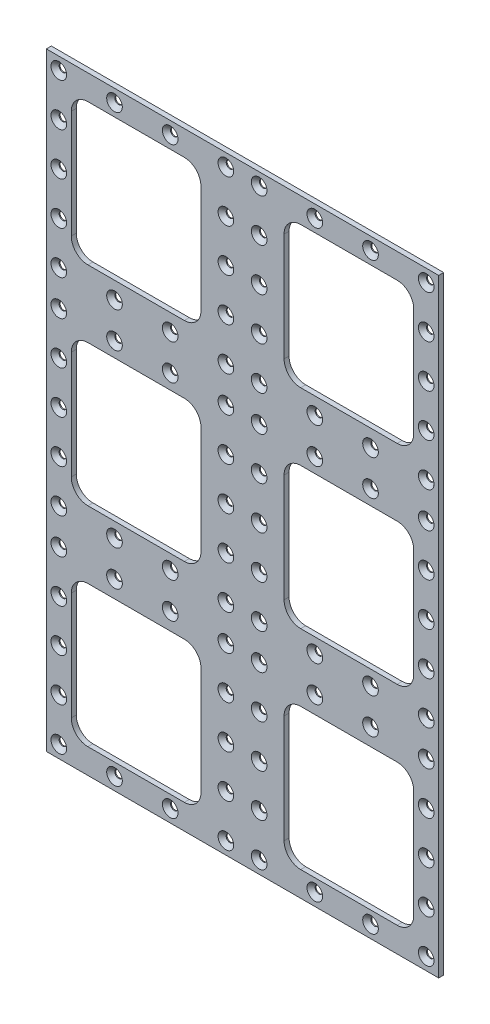
from build123d import *

# Parameters (mm, degrees)
SKETCH1_W              = 236
SKETCH1_H              = 366
BOSS_EXTRUDE1_DEPTH    = 3
SKETCH2_W              = 78
SKETCH2_H              = 85
CUT_EXTRUDE4_DEPTH     = 4
FILLET1_R              = 10
LPATTERN1_COUNT        = 3
LPATTERN1_PITCH        = 125.5
LPATTERN1_COUNT_DIR2   = 2
LPATTERN1_PITCH_DIR2   = 128
FILLET1_OF_LPATTERN1_R = 10
LPATTERN5_COUNT        = 4
LPATTERN5_PITCH        = 33.5
LPATTERN5_COUNT_DIR2   = 5
LPATTERN5_PITCH_DIR2   = 25.6875
LPATTERN6_COUNT        = 3
LPATTERN6_PITCH        = 124.125


with BuildPart() as part:
    # Sketch1 → Boss-Extrude1 (new body)
    with BuildSketch(Plane.XY):
        Rectangle(SKETCH1_W, SKETCH1_H)
    extrude(amount=BOSS_EXTRUDE1_DEPTH)

    # Sketch2 → Cut-Extrude4 (cut, through all)
    with BuildSketch(Plane.XY):
        with Locations((-64, 125.5)):
            Rectangle(SKETCH2_W, SKETCH2_H)
    cut_extrude4 = extrude(amount=CUT_EXTRUDE4_DEPTH, mode=Mode.SUBTRACT)

    # Fillet1
    fillet1_edges = [part.edges().sort_by_distance(p)[0] for p in [
        (-25, 83, 1.5),
        (-25, 168, 1.5),
        (-103, 168, 1.5),
        (-103, 83, 1.5),
    ]]
    fillet(fillet1_edges, radius=FILLET1_R)

    # LPattern1: Cut-Extrude4 3 × 2
    with Locations(*[(j * LPATTERN1_PITCH_DIR2, -i * LPATTERN1_PITCH, 0) for i in range(LPATTERN1_COUNT) for j in range(LPATTERN1_COUNT_DIR2) if (i, j) != (0, 0)]):
        add(cut_extrude4, mode=Mode.SUBTRACT)

    # Fillet1 of LPattern1
    fillet1_of_lpattern1_edges = [part.edges().sort_by_distance(p)[0] for p in [
        (103, 83, 1.5),
        (103, 168, 1.5),
        (25, 168, 1.5),
        (25, 83, 1.5),
        (-25, -42.5, 1.5),
        (-25, 42.5, 1.5),
        (-103, 42.5, 1.5),
        (-103, -42.5, 1.5),
        (103, -42.5, 1.5),
        (103, 42.5, 1.5),
        (25, 42.5, 1.5),
        (25, -42.5, 1.5),
        (-25, -168, 1.5),
        (-25, -83, 1.5),
        (-103, -83, 1.5),
        (-103, -168, 1.5),
        (103, -168, 1.5),
        (103, -83, 1.5),
        (25, -83, 1.5),
        (25, -168, 1.5),
    ]]
    fillet(fillet1_of_lpattern1_edges, radius=FILLET1_OF_LPATTERN1_R)

    # Sketch8 → CSK for M4 Flat Head Machine Screw3 (revolve, cut)
    with BuildSketch(Plane(origin=(-110.5, 175.5, 3), x_dir=(0, -1, 0), z_dir=(1, 0, 0))):
        Polygon((0, 0), (0, 3), (2.25, 3), (2.25, 2.45), (4.7, 0), align=None)
    csk_for_m4_flat_head_machine_screw3 = revolve(axis=Axis((-110.5, 175.5, 9.35), (0, 0, -1)), mode=Mode.SUBTRACT)

    # LPattern5: CSK for M4 Flat Head Machine Screw3 4 × 5, 6 skipped
    with Locations(*[(i * LPATTERN5_PITCH, -j * LPATTERN5_PITCH_DIR2, 0) for i in range(LPATTERN5_COUNT) for j in range(LPATTERN5_COUNT_DIR2) if (i, j) not in ((0, 0), (1, 1), (1, 2), (1, 3), (2, 1), (2, 2), (2, 3))]):
        add(csk_for_m4_flat_head_machine_screw3, mode=Mode.SUBTRACT)

    # LPattern6: CSK for M4 Flat Head Machine Screw3 ×3
    with Locations(*[(0, -i * LPATTERN6_PITCH, 0) for i in range(1, LPATTERN6_COUNT)]):
        add(csk_for_m4_flat_head_machine_screw3, mode=Mode.SUBTRACT)

    # LPattern6 copy 1 sketch → LPattern6 copy 1 (revolve, cut)
    with BuildSketch(Plane(origin=(-110.5, 25.6875, 3), x_dir=(0, -1, 0), z_dir=(1, 0, 0))):
        Polygon((0, 0), (0, 3), (2.25, 3), (2.25, 2.45), (4.7, 0), align=None)
    revolve(axis=Axis((-110.5, 25.6875, 9.35), (0, 0, -1)), mode=Mode.SUBTRACT)

    # LPattern6 copy 2 sketch → LPattern6 copy 2 (revolve, cut)
    with BuildSketch(Plane(origin=(-110.5, -98.4375, 3), x_dir=(0, -1, 0), z_dir=(1, 0, 0))):
        Polygon((0, 0), (0, 3), (2.25, 3), (2.25, 2.45), (4.7, 0), align=None)
    revolve(axis=Axis((-110.5, -98.4375, 9.35), (0, 0, -1)), mode=Mode.SUBTRACT)

    # LPattern6 copy 3 sketch → LPattern6 copy 3 (revolve, cut)
    with BuildSketch(Plane(origin=(-110.5, 0, 3), x_dir=(0, -1, 0), z_dir=(1, 0, 0))):
        Polygon((0, 0), (0, 3), (2.25, 3), (2.25, 2.45), (4.7, 0), align=None)
    revolve(axis=Axis((-110.5, 0, 9.35), (0, 0, -1)), mode=Mode.SUBTRACT)

    # LPattern6 copy 4 sketch → LPattern6 copy 4 (revolve, cut)
    with BuildSketch(Plane(origin=(-110.5, -124.125, 3), x_dir=(0, -1, 0), z_dir=(1, 0, 0))):
        Polygon((0, 0), (0, 3), (2.25, 3), (2.25, 2.45), (4.7, 0), align=None)
    revolve(axis=Axis((-110.5, -124.125, 9.35), (0, 0, -1)), mode=Mode.SUBTRACT)

    # LPattern6 copy 5 sketch → LPattern6 copy 5 (revolve, cut)
    with BuildSketch(Plane(origin=(-110.5, -25.6875, 3), x_dir=(0, -1, 0), z_dir=(1, 0, 0))):
        Polygon((0, 0), (0, 3), (2.25, 3), (2.25, 2.45), (4.7, 0), align=None)
    revolve(axis=Axis((-110.5, -25.6875, 9.35), (0, 0, -1)), mode=Mode.SUBTRACT)

    # LPattern6 copy 6 sketch → LPattern6 copy 6 (revolve, cut)
    with BuildSketch(Plane(origin=(-110.5, -149.8125, 3), x_dir=(0, -1, 0), z_dir=(1, 0, 0))):
        Polygon((0, 0), (0, 3), (2.25, 3), (2.25, 2.45), (4.7, 0), align=None)
    revolve(axis=Axis((-110.5, -149.8125, 9.35), (0, 0, -1)), mode=Mode.SUBTRACT)

    # LPattern6 copy 7 sketch → LPattern6 copy 7 (revolve, cut)
    with BuildSketch(Plane(origin=(-110.5, -51.375, 3), x_dir=(0, -1, 0), z_dir=(1, 0, 0))):
        Polygon((0, 0), (0, 3), (2.25, 3), (2.25, 2.45), (4.7, 0), align=None)
    revolve(axis=Axis((-110.5, -51.375, 9.35), (0, 0, -1)), mode=Mode.SUBTRACT)

    # LPattern6 copy 8 sketch → LPattern6 copy 8 (revolve, cut)
    with BuildSketch(Plane(origin=(-110.5, -175.5, 3), x_dir=(0, -1, 0), z_dir=(1, 0, 0))):
        Polygon((0, 0), (0, 3), (2.25, 3), (2.25, 2.45), (4.7, 0), align=None)
    revolve(axis=Axis((-110.5, -175.5, 9.35), (0, 0, -1)), mode=Mode.SUBTRACT)

    # LPattern6 copy 9 sketch → LPattern6 copy 9 (revolve, cut)
    with BuildSketch(Plane(origin=(-77, 51.375, 3), x_dir=(0, -1, 0), z_dir=(1, 0, 0))):
        Polygon((0, 0), (0, 3), (2.25, 3), (2.25, 2.45), (4.7, 0), align=None)
    revolve(axis=Axis((-77, 51.375, 9.35), (0, 0, -1)), mode=Mode.SUBTRACT)

    # LPattern6 copy 10 sketch → LPattern6 copy 10 (revolve, cut)
    with BuildSketch(Plane(origin=(-77, -72.75, 3), x_dir=(0, -1, 0), z_dir=(1, 0, 0))):
        Polygon((0, 0), (0, 3), (2.25, 3), (2.25, 2.45), (4.7, 0), align=None)
    revolve(axis=Axis((-77, -72.75, 9.35), (0, 0, -1)), mode=Mode.SUBTRACT)

    # LPattern6 copy 11 sketch → LPattern6 copy 11 (revolve, cut)
    with BuildSketch(Plane(origin=(-77, -51.375, 3), x_dir=(0, -1, 0), z_dir=(1, 0, 0))):
        Polygon((0, 0), (0, 3), (2.25, 3), (2.25, 2.45), (4.7, 0), align=None)
    revolve(axis=Axis((-77, -51.375, 9.35), (0, 0, -1)), mode=Mode.SUBTRACT)

    # LPattern6 copy 12 sketch → LPattern6 copy 12 (revolve, cut)
    with BuildSketch(Plane(origin=(-77, -175.5, 3), x_dir=(0, -1, 0), z_dir=(1, 0, 0))):
        Polygon((0, 0), (0, 3), (2.25, 3), (2.25, 2.45), (4.7, 0), align=None)
    revolve(axis=Axis((-77, -175.5, 9.35), (0, 0, -1)), mode=Mode.SUBTRACT)

    # LPattern6 copy 13 sketch → LPattern6 copy 13 (revolve, cut)
    with BuildSketch(Plane(origin=(-43.5, 51.375, 3), x_dir=(0, -1, 0), z_dir=(1, 0, 0))):
        Polygon((0, 0), (0, 3), (2.25, 3), (2.25, 2.45), (4.7, 0), align=None)
    revolve(axis=Axis((-43.5, 51.375, 9.35), (0, 0, -1)), mode=Mode.SUBTRACT)

    # LPattern6 copy 14 sketch → LPattern6 copy 14 (revolve, cut)
    with BuildSketch(Plane(origin=(-43.5, -72.75, 3), x_dir=(0, -1, 0), z_dir=(1, 0, 0))):
        Polygon((0, 0), (0, 3), (2.25, 3), (2.25, 2.45), (4.7, 0), align=None)
    revolve(axis=Axis((-43.5, -72.75, 9.35), (0, 0, -1)), mode=Mode.SUBTRACT)

    # LPattern6 copy 15 sketch → LPattern6 copy 15 (revolve, cut)
    with BuildSketch(Plane(origin=(-43.5, -51.375, 3), x_dir=(0, -1, 0), z_dir=(1, 0, 0))):
        Polygon((0, 0), (0, 3), (2.25, 3), (2.25, 2.45), (4.7, 0), align=None)
    revolve(axis=Axis((-43.5, -51.375, 9.35), (0, 0, -1)), mode=Mode.SUBTRACT)

    # LPattern6 copy 16 sketch → LPattern6 copy 16 (revolve, cut)
    with BuildSketch(Plane(origin=(-43.5, -175.5, 3), x_dir=(0, -1, 0), z_dir=(1, 0, 0))):
        Polygon((0, 0), (0, 3), (2.25, 3), (2.25, 2.45), (4.7, 0), align=None)
    revolve(axis=Axis((-43.5, -175.5, 9.35), (0, 0, -1)), mode=Mode.SUBTRACT)

    # LPattern6 copy 17 sketch → LPattern6 copy 17 (revolve, cut)
    with BuildSketch(Plane(origin=(-10, 51.375, 3), x_dir=(0, -1, 0), z_dir=(1, 0, 0))):
        Polygon((0, 0), (0, 3), (2.25, 3), (2.25, 2.45), (4.7, 0), align=None)
    revolve(axis=Axis((-10, 51.375, 9.35), (0, 0, -1)), mode=Mode.SUBTRACT)

    # LPattern6 copy 18 sketch → LPattern6 copy 18 (revolve, cut)
    with BuildSketch(Plane(origin=(-10, -72.75, 3), x_dir=(0, -1, 0), z_dir=(1, 0, 0))):
        Polygon((0, 0), (0, 3), (2.25, 3), (2.25, 2.45), (4.7, 0), align=None)
    revolve(axis=Axis((-10, -72.75, 9.35), (0, 0, -1)), mode=Mode.SUBTRACT)

    # LPattern6 copy 19 sketch → LPattern6 copy 19 (revolve, cut)
    with BuildSketch(Plane(origin=(-10, 25.6875, 3), x_dir=(0, -1, 0), z_dir=(1, 0, 0))):
        Polygon((0, 0), (0, 3), (2.25, 3), (2.25, 2.45), (4.7, 0), align=None)
    revolve(axis=Axis((-10, 25.6875, 9.35), (0, 0, -1)), mode=Mode.SUBTRACT)

    # LPattern6 copy 20 sketch → LPattern6 copy 20 (revolve, cut)
    with BuildSketch(Plane(origin=(-10, -98.4375, 3), x_dir=(0, -1, 0), z_dir=(1, 0, 0))):
        Polygon((0, 0), (0, 3), (2.25, 3), (2.25, 2.45), (4.7, 0), align=None)
    revolve(axis=Axis((-10, -98.4375, 9.35), (0, 0, -1)), mode=Mode.SUBTRACT)

    # LPattern6 copy 21 sketch → LPattern6 copy 21 (revolve, cut)
    with BuildSketch(Plane(origin=(-10, 0, 3), x_dir=(0, -1, 0), z_dir=(1, 0, 0))):
        Polygon((0, 0), (0, 3), (2.25, 3), (2.25, 2.45), (4.7, 0), align=None)
    revolve(axis=Axis((-10, 0, 9.35), (0, 0, -1)), mode=Mode.SUBTRACT)

    # LPattern6 copy 22 sketch → LPattern6 copy 22 (revolve, cut)
    with BuildSketch(Plane(origin=(-10, -124.125, 3), x_dir=(0, -1, 0), z_dir=(1, 0, 0))):
        Polygon((0, 0), (0, 3), (2.25, 3), (2.25, 2.45), (4.7, 0), align=None)
    revolve(axis=Axis((-10, -124.125, 9.35), (0, 0, -1)), mode=Mode.SUBTRACT)

    # LPattern6 copy 23 sketch → LPattern6 copy 23 (revolve, cut)
    with BuildSketch(Plane(origin=(-10, -25.6875, 3), x_dir=(0, -1, 0), z_dir=(1, 0, 0))):
        Polygon((0, 0), (0, 3), (2.25, 3), (2.25, 2.45), (4.7, 0), align=None)
    revolve(axis=Axis((-10, -25.6875, 9.35), (0, 0, -1)), mode=Mode.SUBTRACT)

    # LPattern6 copy 24 sketch → LPattern6 copy 24 (revolve, cut)
    with BuildSketch(Plane(origin=(-10, -149.8125, 3), x_dir=(0, -1, 0), z_dir=(1, 0, 0))):
        Polygon((0, 0), (0, 3), (2.25, 3), (2.25, 2.45), (4.7, 0), align=None)
    revolve(axis=Axis((-10, -149.8125, 9.35), (0, 0, -1)), mode=Mode.SUBTRACT)

    # LPattern6 copy 25 sketch → LPattern6 copy 25 (revolve, cut)
    with BuildSketch(Plane(origin=(-10, -51.375, 3), x_dir=(0, -1, 0), z_dir=(1, 0, 0))):
        Polygon((0, 0), (0, 3), (2.25, 3), (2.25, 2.45), (4.7, 0), align=None)
    revolve(axis=Axis((-10, -51.375, 9.35), (0, 0, -1)), mode=Mode.SUBTRACT)

    # LPattern6 copy 26 sketch → LPattern6 copy 26 (revolve, cut)
    with BuildSketch(Plane(origin=(-10, -175.5, 3), x_dir=(0, -1, 0), z_dir=(1, 0, 0))):
        Polygon((0, 0), (0, 3), (2.25, 3), (2.25, 2.45), (4.7, 0), align=None)
    revolve(axis=Axis((-10, -175.5, 9.35), (0, 0, -1)), mode=Mode.SUBTRACT)

    # Mirror1: CSK for M4 Flat Head Machine Screw3 across plane
    add(csk_for_m4_flat_head_machine_screw3.mirror(Plane(origin=(0, 0, 0), x_dir=(0, 0, 1), z_dir=(1, 0, 0))), mode=Mode.SUBTRACT)

    # Mirror1 copy 1 sketch → Mirror1 copy 1 (revolve, cut)
    with BuildSketch(Plane(origin=(110.5, 51.375, 3), x_dir=(0, -1, 0), z_dir=(-1, 0, 0))):
        Polygon((0, 0), (0, -3), (2.25, -3), (2.25, -2.45), (4.7, 0), align=None)
    revolve(axis=Axis((110.5, 51.375, 9.35), (0, 0, 1)), mode=Mode.SUBTRACT)

    # Mirror1 copy 2 sketch → Mirror1 copy 2 (revolve, cut)
    with BuildSketch(Plane(origin=(110.5, -72.75, 3), x_dir=(0, -1, 0), z_dir=(-1, 0, 0))):
        Polygon((0, 0), (0, -3), (2.25, -3), (2.25, -2.45), (4.7, 0), align=None)
    revolve(axis=Axis((110.5, -72.75, 9.35), (0, 0, 1)), mode=Mode.SUBTRACT)

    # Mirror1 copy 3 sketch → Mirror1 copy 3 (revolve, cut)
    with BuildSketch(Plane(origin=(110.5, 25.6875, 3), x_dir=(0, -1, 0), z_dir=(-1, 0, 0))):
        Polygon((0, 0), (0, -3), (2.25, -3), (2.25, -2.45), (4.7, 0), align=None)
    revolve(axis=Axis((110.5, 25.6875, 9.35), (0, 0, 1)), mode=Mode.SUBTRACT)

    # Mirror1 copy 4 sketch → Mirror1 copy 4 (revolve, cut)
    with BuildSketch(Plane(origin=(110.5, -98.4375, 3), x_dir=(0, -1, 0), z_dir=(-1, 0, 0))):
        Polygon((0, 0), (0, -3), (2.25, -3), (2.25, -2.45), (4.7, 0), align=None)
    revolve(axis=Axis((110.5, -98.4375, 9.35), (0, 0, 1)), mode=Mode.SUBTRACT)

    # Mirror1 copy 5 sketch → Mirror1 copy 5 (revolve, cut)
    with BuildSketch(Plane(origin=(110.5, 0, 3), x_dir=(0, -1, 0), z_dir=(-1, 0, 0))):
        Polygon((0, 0), (0, -3), (2.25, -3), (2.25, -2.45), (4.7, 0), align=None)
    revolve(axis=Axis((110.5, 0, 9.35), (0, 0, 1)), mode=Mode.SUBTRACT)

    # Mirror1 copy 6 sketch → Mirror1 copy 6 (revolve, cut)
    with BuildSketch(Plane(origin=(110.5, -124.125, 3), x_dir=(0, -1, 0), z_dir=(-1, 0, 0))):
        Polygon((0, 0), (0, -3), (2.25, -3), (2.25, -2.45), (4.7, 0), align=None)
    revolve(axis=Axis((110.5, -124.125, 9.35), (0, 0, 1)), mode=Mode.SUBTRACT)

    # Mirror1 copy 7 sketch → Mirror1 copy 7 (revolve, cut)
    with BuildSketch(Plane(origin=(110.5, -25.6875, 3), x_dir=(0, -1, 0), z_dir=(-1, 0, 0))):
        Polygon((0, 0), (0, -3), (2.25, -3), (2.25, -2.45), (4.7, 0), align=None)
    revolve(axis=Axis((110.5, -25.6875, 9.35), (0, 0, 1)), mode=Mode.SUBTRACT)

    # Mirror1 copy 8 sketch → Mirror1 copy 8 (revolve, cut)
    with BuildSketch(Plane(origin=(110.5, -149.8125, 3), x_dir=(0, -1, 0), z_dir=(-1, 0, 0))):
        Polygon((0, 0), (0, -3), (2.25, -3), (2.25, -2.45), (4.7, 0), align=None)
    revolve(axis=Axis((110.5, -149.8125, 9.35), (0, 0, 1)), mode=Mode.SUBTRACT)

    # Mirror1 copy 9 sketch → Mirror1 copy 9 (revolve, cut)
    with BuildSketch(Plane(origin=(110.5, -51.375, 3), x_dir=(0, -1, 0), z_dir=(-1, 0, 0))):
        Polygon((0, 0), (0, -3), (2.25, -3), (2.25, -2.45), (4.7, 0), align=None)
    revolve(axis=Axis((110.5, -51.375, 9.35), (0, 0, 1)), mode=Mode.SUBTRACT)

    # Mirror1 copy 10 sketch → Mirror1 copy 10 (revolve, cut)
    with BuildSketch(Plane(origin=(110.5, -175.5, 3), x_dir=(0, -1, 0), z_dir=(-1, 0, 0))):
        Polygon((0, 0), (0, -3), (2.25, -3), (2.25, -2.45), (4.7, 0), align=None)
    revolve(axis=Axis((110.5, -175.5, 9.35), (0, 0, 1)), mode=Mode.SUBTRACT)

    # Mirror1 copy 11 sketch → Mirror1 copy 11 (revolve, cut)
    with BuildSketch(Plane(origin=(77, 51.375, 3), x_dir=(0, -1, 0), z_dir=(-1, 0, 0))):
        Polygon((0, 0), (0, -3), (2.25, -3), (2.25, -2.45), (4.7, 0), align=None)
    revolve(axis=Axis((77, 51.375, 9.35), (0, 0, 1)), mode=Mode.SUBTRACT)

    # Mirror1 copy 12 sketch → Mirror1 copy 12 (revolve, cut)
    with BuildSketch(Plane(origin=(77, -72.75, 3), x_dir=(0, -1, 0), z_dir=(-1, 0, 0))):
        Polygon((0, 0), (0, -3), (2.25, -3), (2.25, -2.45), (4.7, 0), align=None)
    revolve(axis=Axis((77, -72.75, 9.35), (0, 0, 1)), mode=Mode.SUBTRACT)

    # Mirror1 copy 13 sketch → Mirror1 copy 13 (revolve, cut)
    with BuildSketch(Plane(origin=(77, -51.375, 3), x_dir=(0, -1, 0), z_dir=(-1, 0, 0))):
        Polygon((0, 0), (0, -3), (2.25, -3), (2.25, -2.45), (4.7, 0), align=None)
    revolve(axis=Axis((77, -51.375, 9.35), (0, 0, 1)), mode=Mode.SUBTRACT)

    # Mirror1 copy 14 sketch → Mirror1 copy 14 (revolve, cut)
    with BuildSketch(Plane(origin=(77, -175.5, 3), x_dir=(0, -1, 0), z_dir=(-1, 0, 0))):
        Polygon((0, 0), (0, -3), (2.25, -3), (2.25, -2.45), (4.7, 0), align=None)
    revolve(axis=Axis((77, -175.5, 9.35), (0, 0, 1)), mode=Mode.SUBTRACT)

    # Mirror1 copy 15 sketch → Mirror1 copy 15 (revolve, cut)
    with BuildSketch(Plane(origin=(43.5, 51.375, 3), x_dir=(0, -1, 0), z_dir=(-1, 0, 0))):
        Polygon((0, 0), (0, -3), (2.25, -3), (2.25, -2.45), (4.7, 0), align=None)
    revolve(axis=Axis((43.5, 51.375, 9.35), (0, 0, 1)), mode=Mode.SUBTRACT)

    # Mirror1 copy 16 sketch → Mirror1 copy 16 (revolve, cut)
    with BuildSketch(Plane(origin=(43.5, -72.75, 3), x_dir=(0, -1, 0), z_dir=(-1, 0, 0))):
        Polygon((0, 0), (0, -3), (2.25, -3), (2.25, -2.45), (4.7, 0), align=None)
    revolve(axis=Axis((43.5, -72.75, 9.35), (0, 0, 1)), mode=Mode.SUBTRACT)

    # Mirror1 copy 17 sketch → Mirror1 copy 17 (revolve, cut)
    with BuildSketch(Plane(origin=(43.5, -51.375, 3), x_dir=(0, -1, 0), z_dir=(-1, 0, 0))):
        Polygon((0, 0), (0, -3), (2.25, -3), (2.25, -2.45), (4.7, 0), align=None)
    revolve(axis=Axis((43.5, -51.375, 9.35), (0, 0, 1)), mode=Mode.SUBTRACT)

    # Mirror1 copy 18 sketch → Mirror1 copy 18 (revolve, cut)
    with BuildSketch(Plane(origin=(43.5, -175.5, 3), x_dir=(0, -1, 0), z_dir=(-1, 0, 0))):
        Polygon((0, 0), (0, -3), (2.25, -3), (2.25, -2.45), (4.7, 0), align=None)
    revolve(axis=Axis((43.5, -175.5, 9.35), (0, 0, 1)), mode=Mode.SUBTRACT)

    # Mirror1 copy 19 sketch → Mirror1 copy 19 (revolve, cut)
    with BuildSketch(Plane(origin=(10, 51.375, 3), x_dir=(0, -1, 0), z_dir=(-1, 0, 0))):
        Polygon((0, 0), (0, -3), (2.25, -3), (2.25, -2.45), (4.7, 0), align=None)
    revolve(axis=Axis((10, 51.375, 9.35), (0, 0, 1)), mode=Mode.SUBTRACT)

    # Mirror1 copy 20 sketch → Mirror1 copy 20 (revolve, cut)
    with BuildSketch(Plane(origin=(10, -72.75, 3), x_dir=(0, -1, 0), z_dir=(-1, 0, 0))):
        Polygon((0, 0), (0, -3), (2.25, -3), (2.25, -2.45), (4.7, 0), align=None)
    revolve(axis=Axis((10, -72.75, 9.35), (0, 0, 1)), mode=Mode.SUBTRACT)

    # Mirror1 copy 21 sketch → Mirror1 copy 21 (revolve, cut)
    with BuildSketch(Plane(origin=(10, 25.6875, 3), x_dir=(0, -1, 0), z_dir=(-1, 0, 0))):
        Polygon((0, 0), (0, -3), (2.25, -3), (2.25, -2.45), (4.7, 0), align=None)
    revolve(axis=Axis((10, 25.6875, 9.35), (0, 0, 1)), mode=Mode.SUBTRACT)

    # Mirror1 copy 22 sketch → Mirror1 copy 22 (revolve, cut)
    with BuildSketch(Plane(origin=(10, -98.4375, 3), x_dir=(0, -1, 0), z_dir=(-1, 0, 0))):
        Polygon((0, 0), (0, -3), (2.25, -3), (2.25, -2.45), (4.7, 0), align=None)
    revolve(axis=Axis((10, -98.4375, 9.35), (0, 0, 1)), mode=Mode.SUBTRACT)

    # Mirror1 copy 23 sketch → Mirror1 copy 23 (revolve, cut)
    with BuildSketch(Plane(origin=(10, 0, 3), x_dir=(0, -1, 0), z_dir=(-1, 0, 0))):
        Polygon((0, 0), (0, -3), (2.25, -3), (2.25, -2.45), (4.7, 0), align=None)
    revolve(axis=Axis((10, 0, 9.35), (0, 0, 1)), mode=Mode.SUBTRACT)

    # Mirror1 copy 24 sketch → Mirror1 copy 24 (revolve, cut)
    with BuildSketch(Plane(origin=(10, -124.125, 3), x_dir=(0, -1, 0), z_dir=(-1, 0, 0))):
        Polygon((0, 0), (0, -3), (2.25, -3), (2.25, -2.45), (4.7, 0), align=None)
    revolve(axis=Axis((10, -124.125, 9.35), (0, 0, 1)), mode=Mode.SUBTRACT)

    # Mirror1 copy 25 sketch → Mirror1 copy 25 (revolve, cut)
    with BuildSketch(Plane(origin=(10, -25.6875, 3), x_dir=(0, -1, 0), z_dir=(-1, 0, 0))):
        Polygon((0, 0), (0, -3), (2.25, -3), (2.25, -2.45), (4.7, 0), align=None)
    revolve(axis=Axis((10, -25.6875, 9.35), (0, 0, 1)), mode=Mode.SUBTRACT)

    # Mirror1 copy 26 sketch → Mirror1 copy 26 (revolve, cut)
    with BuildSketch(Plane(origin=(10, -149.8125, 3), x_dir=(0, -1, 0), z_dir=(-1, 0, 0))):
        Polygon((0, 0), (0, -3), (2.25, -3), (2.25, -2.45), (4.7, 0), align=None)
    revolve(axis=Axis((10, -149.8125, 9.35), (0, 0, 1)), mode=Mode.SUBTRACT)

    # Mirror1 copy 27 sketch → Mirror1 copy 27 (revolve, cut)
    with BuildSketch(Plane(origin=(10, -51.375, 3), x_dir=(0, -1, 0), z_dir=(-1, 0, 0))):
        Polygon((0, 0), (0, -3), (2.25, -3), (2.25, -2.45), (4.7, 0), align=None)
    revolve(axis=Axis((10, -51.375, 9.35), (0, 0, 1)), mode=Mode.SUBTRACT)

    # Mirror1 copy 28 sketch → Mirror1 copy 28 (revolve, cut)
    with BuildSketch(Plane(origin=(10, -175.5, 3), x_dir=(0, -1, 0), z_dir=(-1, 0, 0))):
        Polygon((0, 0), (0, -3), (2.25, -3), (2.25, -2.45), (4.7, 0), align=None)
    revolve(axis=Axis((10, -175.5, 9.35), (0, 0, 1)), mode=Mode.SUBTRACT)

    # Mirror1 copy 29 sketch → Mirror1 copy 29 (revolve, cut)
    with BuildSketch(Plane(origin=(110.5, 149.8125, 3), x_dir=(0, -1, 0), z_dir=(-1, 0, 0))):
        Polygon((0, 0), (0, -3), (2.25, -3), (2.25, -2.45), (4.7, 0), align=None)
    revolve(axis=Axis((110.5, 149.8125, 9.35), (0, 0, 1)), mode=Mode.SUBTRACT)

    # Mirror1 copy 30 sketch → Mirror1 copy 30 (revolve, cut)
    with BuildSketch(Plane(origin=(110.5, 124.125, 3), x_dir=(0, -1, 0), z_dir=(-1, 0, 0))):
        Polygon((0, 0), (0, -3), (2.25, -3), (2.25, -2.45), (4.7, 0), align=None)
    revolve(axis=Axis((110.5, 124.125, 9.35), (0, 0, 1)), mode=Mode.SUBTRACT)

    # Mirror1 copy 31 sketch → Mirror1 copy 31 (revolve, cut)
    with BuildSketch(Plane(origin=(110.5, 98.4375, 3), x_dir=(0, -1, 0), z_dir=(-1, 0, 0))):
        Polygon((0, 0), (0, -3), (2.25, -3), (2.25, -2.45), (4.7, 0), align=None)
    revolve(axis=Axis((110.5, 98.4375, 9.35), (0, 0, 1)), mode=Mode.SUBTRACT)

    # Mirror1 copy 32 sketch → Mirror1 copy 32 (revolve, cut)
    with BuildSketch(Plane(origin=(110.5, 72.75, 3), x_dir=(0, -1, 0), z_dir=(-1, 0, 0))):
        Polygon((0, 0), (0, -3), (2.25, -3), (2.25, -2.45), (4.7, 0), align=None)
    revolve(axis=Axis((110.5, 72.75, 9.35), (0, 0, 1)), mode=Mode.SUBTRACT)

    # Mirror1 copy 33 sketch → Mirror1 copy 33 (revolve, cut)
    with BuildSketch(Plane(origin=(77, 175.5, 3), x_dir=(0, -1, 0), z_dir=(-1, 0, 0))):
        Polygon((0, 0), (0, -3), (2.25, -3), (2.25, -2.45), (4.7, 0), align=None)
    revolve(axis=Axis((77, 175.5, 9.35), (0, 0, 1)), mode=Mode.SUBTRACT)

    # Mirror1 copy 34 sketch → Mirror1 copy 34 (revolve, cut)
    with BuildSketch(Plane(origin=(77, 72.75, 3), x_dir=(0, -1, 0), z_dir=(-1, 0, 0))):
        Polygon((0, 0), (0, -3), (2.25, -3), (2.25, -2.45), (4.7, 0), align=None)
    revolve(axis=Axis((77, 72.75, 9.35), (0, 0, 1)), mode=Mode.SUBTRACT)

    # Mirror1 copy 35 sketch → Mirror1 copy 35 (revolve, cut)
    with BuildSketch(Plane(origin=(43.5, 175.5, 3), x_dir=(0, -1, 0), z_dir=(-1, 0, 0))):
        Polygon((0, 0), (0, -3), (2.25, -3), (2.25, -2.45), (4.7, 0), align=None)
    revolve(axis=Axis((43.5, 175.5, 9.35), (0, 0, 1)), mode=Mode.SUBTRACT)

    # Mirror1 copy 36 sketch → Mirror1 copy 36 (revolve, cut)
    with BuildSketch(Plane(origin=(43.5, 72.75, 3), x_dir=(0, -1, 0), z_dir=(-1, 0, 0))):
        Polygon((0, 0), (0, -3), (2.25, -3), (2.25, -2.45), (4.7, 0), align=None)
    revolve(axis=Axis((43.5, 72.75, 9.35), (0, 0, 1)), mode=Mode.SUBTRACT)

    # Mirror1 copy 37 sketch → Mirror1 copy 37 (revolve, cut)
    with BuildSketch(Plane(origin=(10, 175.5, 3), x_dir=(0, -1, 0), z_dir=(-1, 0, 0))):
        Polygon((0, 0), (0, -3), (2.25, -3), (2.25, -2.45), (4.7, 0), align=None)
    revolve(axis=Axis((10, 175.5, 9.35), (0, 0, 1)), mode=Mode.SUBTRACT)

    # Mirror1 copy 38 sketch → Mirror1 copy 38 (revolve, cut)
    with BuildSketch(Plane(origin=(10, 149.8125, 3), x_dir=(0, -1, 0), z_dir=(-1, 0, 0))):
        Polygon((0, 0), (0, -3), (2.25, -3), (2.25, -2.45), (4.7, 0), align=None)
    revolve(axis=Axis((10, 149.8125, 9.35), (0, 0, 1)), mode=Mode.SUBTRACT)

    # Mirror1 copy 39 sketch → Mirror1 copy 39 (revolve, cut)
    with BuildSketch(Plane(origin=(10, 124.125, 3), x_dir=(0, -1, 0), z_dir=(-1, 0, 0))):
        Polygon((0, 0), (0, -3), (2.25, -3), (2.25, -2.45), (4.7, 0), align=None)
    revolve(axis=Axis((10, 124.125, 9.35), (0, 0, 1)), mode=Mode.SUBTRACT)

    # Mirror1 copy 40 sketch → Mirror1 copy 40 (revolve, cut)
    with BuildSketch(Plane(origin=(10, 98.4375, 3), x_dir=(0, -1, 0), z_dir=(-1, 0, 0))):
        Polygon((0, 0), (0, -3), (2.25, -3), (2.25, -2.45), (4.7, 0), align=None)
    revolve(axis=Axis((10, 98.4375, 9.35), (0, 0, 1)), mode=Mode.SUBTRACT)

    # Mirror1 copy 41 sketch → Mirror1 copy 41 (revolve, cut)
    with BuildSketch(Plane(origin=(10, 72.75, 3), x_dir=(0, -1, 0), z_dir=(-1, 0, 0))):
        Polygon((0, 0), (0, -3), (2.25, -3), (2.25, -2.45), (4.7, 0), align=None)
    revolve(axis=Axis((10, 72.75, 9.35), (0, 0, 1)), mode=Mode.SUBTRACT)


solid = part.part
